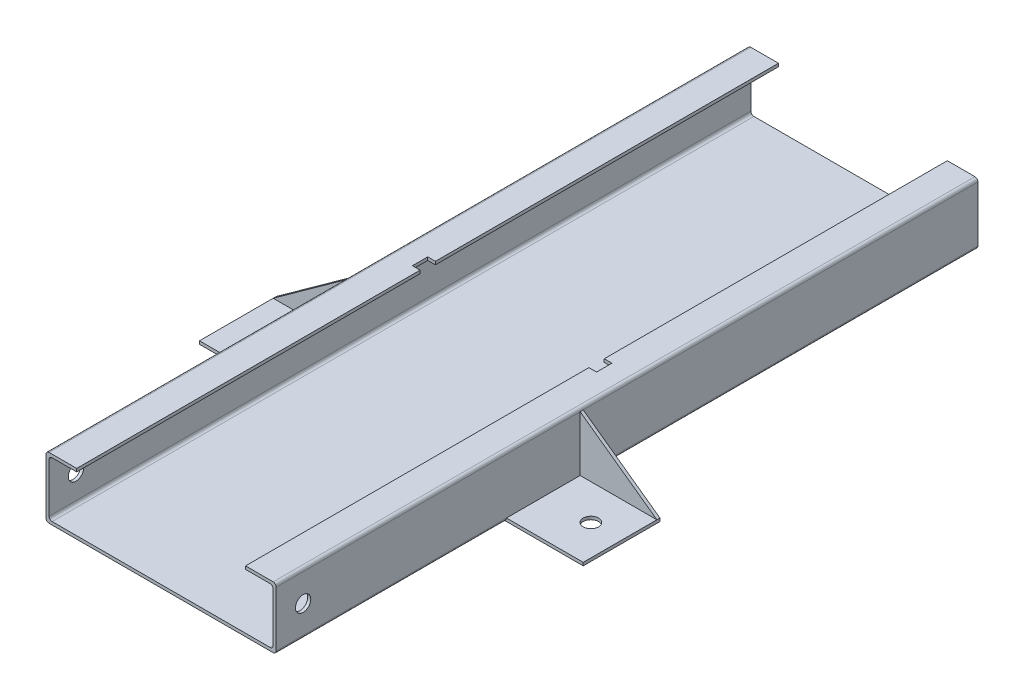
from build123d import *

# Parameters (mm, degrees)
SALIENTE_EXTRUIR2_DEPTH = 228.6
REDONDEO1_R             = 2
CROQUIS3_R              = 5
CORTAR_EXTRUIR1_DEPTH   = 151
SALIENTE_EXTRUIR3_START = -3
CROQUIS5_W              = 50
CROQUIS5_H              = 2
SALIENTE_EXTRUIR3_DEPTH = 53
CROQUIS6_R              = 5
CORTAR_EXTRUIR2_DEPTH   = 50
SALIENTE_EXTRUIR4_DEPTH = 2
CROQUIS8_W              = 5
CROQUIS8_H              = 10
CORTAR_EXTRUIR3_DEPTH   = 10


with BuildPart() as part:
    # Croquis2 → Saliente-Extruir2 (new body, symmetric)
    with BuildSketch(Plane.XY):
        Polygon((-75, 20), (-55, 20), (-55, 18), (-73, 18), (-73, -18), (73, -18), (73, 18), (55, 18), (55, 20), (75, 20), (75, -20), (-75, -20), align=None)
    extrude(amount=SALIENTE_EXTRUIR2_DEPTH, both=True)

    # Redondeo1
    redondeo1_edges = [part.edges().sort_by_distance(p)[0] for p in [
        (75, 20, 0),
        (75, -20, 0),
        (-75, -20, 0),
        (-75, 20, 0),
        (-73, 18, 0),
        (-73, -18, 0),
        (73, -18, 0),
        (73, 18, 0),
    ]]
    fillet(redondeo1_edges, radius=REDONDEO1_R)

    # Croquis3 → Cortar-Extruir1 (cut, through all)
    with BuildSketch(Plane(origin=(75, 0, 0), x_dir=(0, 0, -1), z_dir=(1, 0, 0))):
        with Locations((-211.1, 0)):
            Circle(CROQUIS3_R)
    extrude(amount=-CORTAR_EXTRUIR1_DEPTH, mode=Mode.SUBTRACT)

    # Croquis5 → Saliente-Extruir3 (add)
    with BuildSketch(Plane(origin=(75, 0, 0), x_dir=(0, 0, -1), z_dir=(1, 0, 0)).offset(SALIENTE_EXTRUIR3_START)):
        with Locations((-53.6, -19)):
            Rectangle(CROQUIS5_W, CROQUIS5_H)
    saliente_extruir3 = extrude(amount=SALIENTE_EXTRUIR3_DEPTH)

    # Croquis6 → Cortar-Extruir2 (cut)
    with BuildSketch(Plane(origin=(0, -18, 0), x_dir=(1, 0, 0), z_dir=(0, 1, 0))):
        with Locations((105, -53.6)):
            Circle(CROQUIS6_R)
    cortar_extruir2 = extrude(amount=-CORTAR_EXTRUIR2_DEPTH, mode=Mode.SUBTRACT)

    # Croquis7 → Saliente-Extruir4 (add)
    with BuildSketch(Plane(origin=(0, 0, 28.6), x_dir=(-1, 0, 0), z_dir=(0, 0, -1))):
        Polygon((-75, -18), (-75, 18), (-125, -18), align=None)
    saliente_extruir4 = extrude(amount=-SALIENTE_EXTRUIR4_DEPTH)

    # Simetría1: Saliente-Extruir3, Cortar-Extruir2, Saliente-Extruir4 across plane
    add(saliente_extruir3.mirror(Plane(origin=(0, 0, 0), x_dir=(0, 0, 1), z_dir=(1, 0, 0))))
    add(cortar_extruir2.mirror(Plane(origin=(0, 0, 0), x_dir=(0, 0, 1), z_dir=(1, 0, 0))), mode=Mode.SUBTRACT)
    add(saliente_extruir4.mirror(Plane(origin=(0, 0, 0), x_dir=(0, 0, 1), z_dir=(1, 0, 0))))

    # Croquis8 → Cortar-Extruir3 (cut)
    with BuildSketch(Plane(origin=(0, 20, 0), x_dir=(1, 0, 0), z_dir=(0, 1, 0))):
        with Locations((-57.5, 0.1)):
            Rectangle(CROQUIS8_W, CROQUIS8_H)
        with Locations((57.5, 0.1)):
            Rectangle(CROQUIS8_W, CROQUIS8_H)
    extrude(amount=-CORTAR_EXTRUIR3_DEPTH, mode=Mode.SUBTRACT)


solid = part.part
